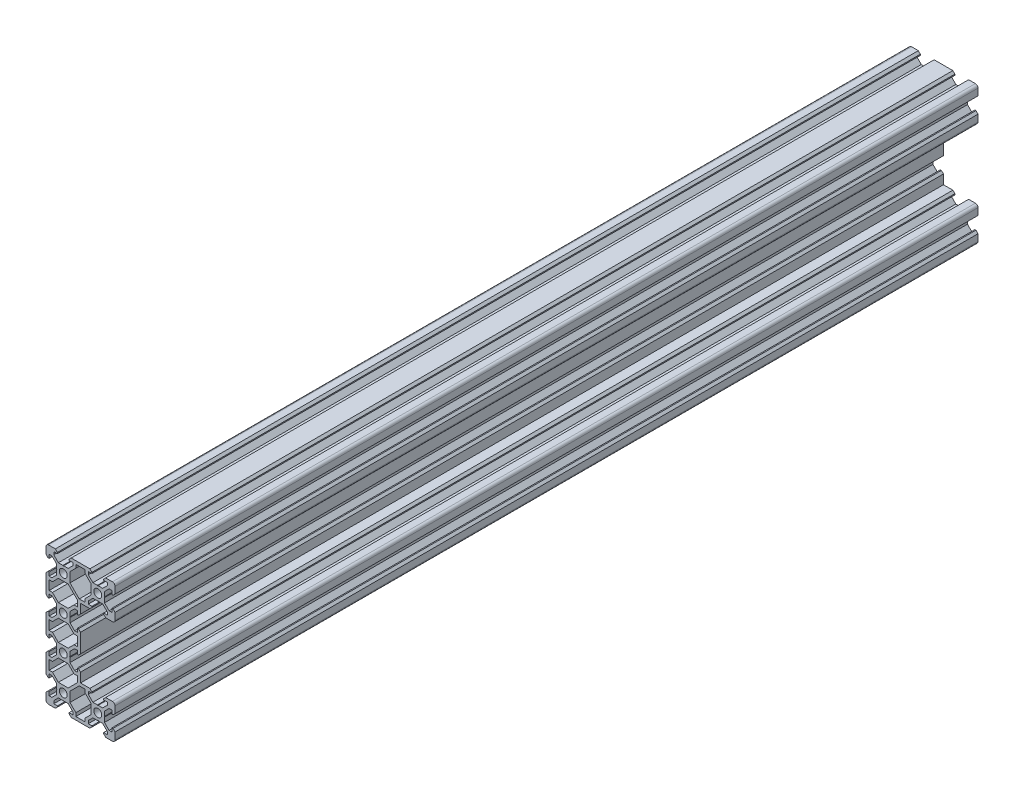
from build123d import *

# Parameters (mm, degrees)
SKETCH1_R           = 2.3
BOSS_EXTRUDE1_DEPTH = 500


with BuildPart() as part:
    # Sketch1 → Boss-Extrude1 (new body)
    with BuildSketch(Plane.XY):
        with BuildLine():
            Line((0, -5.42), (0, 5.42))
            Line((0, 5.42), (1.185, 6.605))
            Line((1.185, 6.605), (1.8, 6.605))
            Line((1.8, 6.605), (1.8, 4.5))
            Line((1.8, 4.5), (3.439339828, 4.5))
            Line((3.439339828, 4.5), (6.1, 7.160660172))
            Line((6.1, 7.160660172), (6.1, 9.79))
            Line((6.1, 9.79), (6.31, 10))
            Line((6.31, 10), (6.1, 10.21))
            Line((6.1, 10.21), (6.1, 12.839339828))
            Line((6.1, 12.839339828), (3.439339828, 15.5))
            Line((3.439339828, 15.5), (1.8, 15.5))
            Line((1.8, 15.5), (1.8, 13.395))
            Line((1.8, 13.395), (1.185, 13.395))
            Line((1.185, 13.395), (0, 14.58))
            Line((0, 14.58), (0, 25.42))
            Line((0, 25.42), (1.185, 26.605))
            Line((1.185, 26.605), (1.8, 26.605))
            Line((1.8, 26.605), (1.8, 24.5))
            Line((1.8, 24.5), (3.439339828, 24.5))
            Line((3.439339828, 24.5), (6.1, 27.160660172))
            Line((6.1, 27.160660172), (6.1, 29.79))
            Line((6.1, 29.79), (6.31, 30))
            Line((6.31, 30), (6.1, 30.21))
            Line((6.1, 30.21), (6.1, 32.839339828))
            Line((6.1, 32.839339828), (3.439339828, 35.5))
            Line((3.439339828, 35.5), (1.8, 35.5))
            Line((1.8, 35.5), (1.8, 33.395))
            Line((1.8, 33.395), (1.185, 33.395))
            Line((1.185, 33.395), (0, 34.58))
            Line((0, 34.58), (0, 38.5))
            ThreePointArc((0, 38.5), (0.439339828, 39.560660172), (1.5, 40))
            Line((1.5, 40), (5.42, 40))
            Line((5.42, 40), (6.605, 38.815))
            Line((6.605, 38.815), (6.605, 38.2))
            Line((6.605, 38.2), (4.5, 38.2))
            Line((4.5, 38.2), (4.5, 36.560660172))
            Line((4.5, 36.560660172), (7.160660172, 33.9))
            Line((7.160660172, 33.9), (9.79, 33.9))
            Line((9.79, 33.9), (10, 33.69))
            Line((10, 33.69), (10.21, 33.9))
            Line((10.21, 33.9), (12.839339828, 33.9))
            Line((12.839339828, 33.9), (15.5, 36.560660172))
            Line((15.5, 36.560660172), (15.5, 38.2))
            Line((15.5, 38.2), (13.395, 38.2))
            Line((13.395, 38.2), (13.395, 38.815))
            Line((13.395, 38.815), (14.58, 40))
            Line((14.58, 40), (25.42, 40))
            Line((25.42, 40), (26.605, 38.815))
            Line((26.605, 38.815), (26.605, 38.2))
            Line((26.605, 38.2), (24.5, 38.2))
            Line((24.5, 38.2), (24.5, 36.560660172))
            Line((24.5, 36.560660172), (27.160660172, 33.9))
            Line((27.160660172, 33.9), (29.79, 33.9))
            Line((29.79, 33.9), (30, 33.69))
            Line((30, 33.69), (30.21, 33.9))
            Line((30.21, 33.9), (32.839339828, 33.9))
            Line((32.839339828, 33.9), (35.5, 36.560660172))
            Line((35.5, 36.560660172), (35.5, 38.2))
            Line((35.5, 38.2), (33.395, 38.2))
            Line((33.395, 38.2), (33.395, 38.815))
            Line((33.395, 38.815), (34.58, 40))
            Line((34.58, 40), (38.5, 40))
            ThreePointArc((38.5, 40), (39.560660172, 39.560660172), (40, 38.5))
            Line((40, 38.5), (40, 34.58))
            Line((40, 34.58), (38.815, 33.395))
            Line((38.815, 33.395), (38.2, 33.395))
            Line((38.2, 33.395), (38.2, 35.5))
            Line((38.2, 35.5), (36.560660172, 35.5))
            Line((36.560660172, 35.5), (33.9, 32.839339828))
            Line((33.9, 32.839339828), (33.9, 30.21))
            Line((33.9, 30.21), (33.69, 30))
            Line((33.69, 30), (33.9, 29.79))
            Line((33.9, 29.79), (33.9, 27.160660172))
            Line((33.9, 27.160660172), (36.560660172, 24.5))
            Line((36.560660172, 24.5), (38.2, 24.5))
            Line((38.2, 24.5), (38.2, 26.605))
            Line((38.2, 26.605), (38.815, 26.605))
            Line((38.815, 26.605), (40, 25.42))
            Line((40, 25.42), (40, 21.5))
            ThreePointArc((40, 21.5), (39.560660172, 20.439339828), (38.5, 20))
            Line((38.5, 20), (34.58, 20))
            Line((34.58, 20), (33.395, 21.185))
            Line((33.395, 21.185), (33.395, 21.8))
            Line((33.395, 21.8), (35.5, 21.8))
            Line((35.5, 21.8), (35.5, 23.439339828))
            Line((35.5, 23.439339828), (32.839339828, 26.1))
            Line((32.839339828, 26.1), (30.21, 26.1))
            Line((30.21, 26.1), (30, 26.31))
            Line((30, 26.31), (29.79, 26.1))
            Line((29.79, 26.1), (27.160660172, 26.1))
            Line((27.160660172, 26.1), (24.5, 23.439339828))
            Line((24.5, 23.439339828), (24.5, 21.8))
            Line((24.5, 21.8), (26.605, 21.8))
            Line((26.605, 21.8), (26.605, 21.185))
            Line((26.605, 21.185), (25.42, 20))
            Line((25.42, 20), (20, 20))
            Line((20, 20), (20, 14.58))
            Line((20, 14.58), (18.815, 13.395))
            Line((18.815, 13.395), (18.2, 13.395))
            Line((18.2, 13.395), (18.2, 15.5))
            Line((18.2, 15.5), (16.560660172, 15.5))
            Line((16.560660172, 15.5), (13.9, 12.839339828))
            Line((13.9, 12.839339828), (13.9, 10.21))
            Line((13.9, 10.21), (13.69, 10))
            Line((13.69, 10), (13.9, 9.79))
            Line((13.9, 9.79), (13.9, 7.160660172))
            Line((13.9, 7.160660172), (16.560660172, 4.5))
            Line((16.560660172, 4.5), (18.2, 4.5))
            Line((18.2, 4.5), (18.2, 6.605))
            Line((18.2, 6.605), (18.815, 6.605))
            Line((18.815, 6.605), (20, 5.42))
            Line((20, 5.42), (20, -5.42))
            Line((20, -5.42), (18.815, -6.605))
            Line((18.815, -6.605), (18.2, -6.605))
            Line((18.2, -6.605), (18.2, -4.5))
            Line((18.2, -4.5), (16.560660172, -4.5))
            Line((16.560660172, -4.5), (13.9, -7.160660172))
            Line((13.9, -7.160660172), (13.9, -9.79))
            Line((13.9, -9.79), (13.69, -10))
            Line((13.69, -10), (13.9, -10.21))
            Line((13.9, -10.21), (13.9, -12.839339828))
            Line((13.9, -12.839339828), (16.560660172, -15.5))
            Line((16.560660172, -15.5), (18.2, -15.5))
            Line((18.2, -15.5), (18.2, -13.395))
            Line((18.2, -13.395), (18.815, -13.395))
            Line((18.815, -13.395), (20, -14.58))
            Line((20, -14.58), (20, -20))
            Line((20, -20), (25.42, -20))
            Line((25.42, -20), (26.605, -21.185))
            Line((26.605, -21.185), (26.605, -21.8))
            Line((26.605, -21.8), (24.5, -21.8))
            Line((24.5, -21.8), (24.5, -23.439339828))
            Line((24.5, -23.439339828), (27.160660172, -26.1))
            Line((27.160660172, -26.1), (29.79, -26.1))
            Line((29.79, -26.1), (30, -26.31))
            Line((30, -26.31), (30.21, -26.1))
            Line((30.21, -26.1), (32.839339828, -26.1))
            Line((32.839339828, -26.1), (35.5, -23.439339828))
            Line((35.5, -23.439339828), (35.5, -21.8))
            Line((35.5, -21.8), (33.395, -21.8))
            Line((33.395, -21.8), (33.395, -21.185))
            Line((33.395, -21.185), (34.58, -20))
            Line((34.58, -20), (38.5, -20))
            ThreePointArc((38.5, -20), (39.560660172, -20.439339828), (40, -21.5))
            Line((40, -21.5), (40, -25.42))
            Line((40, -25.42), (38.815, -26.605))
            Line((38.815, -26.605), (38.2, -26.605))
            Line((38.2, -26.605), (38.2, -24.5))
            Line((38.2, -24.5), (36.560660172, -24.5))
            Line((36.560660172, -24.5), (33.9, -27.160660172))
            Line((33.9, -27.160660172), (33.9, -29.79))
            Line((33.9, -29.79), (33.69, -30))
            Line((33.69, -30), (33.9, -30.21))
            Line((33.9, -30.21), (33.9, -32.839339828))
            Line((33.9, -32.839339828), (36.560660172, -35.5))
            Line((36.560660172, -35.5), (38.2, -35.5))
            Line((38.2, -35.5), (38.2, -33.395))
            Line((38.2, -33.395), (38.815, -33.395))
            Line((38.815, -33.395), (40, -34.58))
            Line((40, -34.58), (40, -38.5))
            ThreePointArc((40, -38.5), (39.560660172, -39.560660172), (38.5, -40))
            Line((38.5, -40), (34.58, -40))
            Line((34.58, -40), (33.395, -38.815))
            Line((33.395, -38.815), (33.395, -38.2))
            Line((33.395, -38.2), (35.5, -38.2))
            Line((35.5, -38.2), (35.5, -36.560660172))
            Line((35.5, -36.560660172), (32.839339828, -33.9))
            Line((32.839339828, -33.9), (30.21, -33.9))
            Line((30.21, -33.9), (30, -33.69))
            Line((30, -33.69), (29.79, -33.9))
            Line((29.79, -33.9), (27.160660172, -33.9))
            Line((27.160660172, -33.9), (24.5, -36.560660172))
            Line((24.5, -36.560660172), (24.5, -38.2))
            Line((24.5, -38.2), (26.605, -38.2))
            Line((26.605, -38.2), (26.605, -38.815))
            Line((26.605, -38.815), (25.42, -40))
            Line((25.42, -40), (14.58, -40))
            Line((14.58, -40), (13.395, -38.815))
            Line((13.395, -38.815), (13.395, -38.2))
            Line((13.395, -38.2), (15.5, -38.2))
            Line((15.5, -38.2), (15.5, -36.560660172))
            Line((15.5, -36.560660172), (12.839339828, -33.9))
            Line((12.839339828, -33.9), (10.21, -33.9))
            Line((10.21, -33.9), (10, -33.69))
            Line((10, -33.69), (9.79, -33.9))
            Line((9.79, -33.9), (7.160660172, -33.9))
            Line((7.160660172, -33.9), (4.5, -36.560660172))
            Line((4.5, -36.560660172), (4.5, -38.2))
            Line((4.5, -38.2), (6.605, -38.2))
            Line((6.605, -38.2), (6.605, -38.815))
            Line((6.605, -38.815), (5.42, -40))
            Line((5.42, -40), (1.5, -40))
            ThreePointArc((1.5, -40), (0.439339828, -39.560660172), (0, -38.5))
            Line((0, -38.5), (0, -34.58))
            Line((0, -34.58), (1.185, -33.395))
            Line((1.185, -33.395), (1.8, -33.395))
            Line((1.8, -33.395), (1.8, -35.5))
            Line((1.8, -35.5), (3.439339828, -35.5))
            Line((3.439339828, -35.5), (6.1, -32.839339828))
            Line((6.1, -32.839339828), (6.1, -30.21))
            Line((6.1, -30.21), (6.31, -30))
            Line((6.31, -30), (6.1, -29.79))
            Line((6.1, -29.79), (6.1, -27.160660172))
            Line((6.1, -27.160660172), (3.439339828, -24.5))
            Line((3.439339828, -24.5), (1.8, -24.5))
            Line((1.8, -24.5), (1.8, -26.605))
            Line((1.8, -26.605), (1.185, -26.605))
            Line((1.185, -26.605), (0, -25.42))
            Line((0, -25.42), (0, -14.58))
            Line((0, -14.58), (1.185, -13.395))
            Line((1.185, -13.395), (1.8, -13.395))
            Line((1.8, -13.395), (1.8, -15.5))
            Line((1.8, -15.5), (3.439339828, -15.5))
            Line((3.439339828, -15.5), (6.1, -12.839339828))
            Line((6.1, -12.839339828), (6.1, -10.21))
            Line((6.1, -10.21), (6.31, -10))
            Line((6.31, -10), (6.1, -9.79))
            Line((6.1, -9.79), (6.1, -7.160660172))
            Line((6.1, -7.160660172), (3.439339828, -4.5))
            Line((3.439339828, -4.5), (1.8, -4.5))
            Line((1.8, -4.5), (1.8, -6.605))
            Line((1.8, -6.605), (1.185, -6.605))
            Line((1.185, -6.605), (0, -5.42))
        make_face()
        with Locations((30, -30)):
            Circle(SKETCH1_R, mode=Mode.SUBTRACT)
        with Locations((30, 30)):
            Circle(SKETCH1_R, mode=Mode.SUBTRACT)
        with Locations((10, 30)):
            Circle(SKETCH1_R, mode=Mode.SUBTRACT)
        with Locations((10, 10)):
            Circle(SKETCH1_R, mode=Mode.SUBTRACT)
        with Locations((10, -10)):
            Circle(SKETCH1_R, mode=Mode.SUBTRACT)
        with Locations((10, -30)):
            Circle(SKETCH1_R, mode=Mode.SUBTRACT)
        Polygon((17.3, 38.2), (17.3, 36.239339828), (13.9, 32.839339828), (13.9, 27.160660172), (19.260660172, 21.8), (22.7, 21.8), (22.7, 23.760660172), (26.1, 27.160660172), (26.1, 32.839339828), (22.7, 36.239339828), (22.7, 38.2), align=None, mode=Mode.SUBTRACT)
        Polygon((1.8, -22.7), (3.760660172, -22.7), (7.160660172, -26.1), (12.839339828, -26.1), (18.2, -20.739339828), (18.2, -17.3), (16.239339828, -17.3), (12.839339828, -13.9), (7.160660172, -13.9), (3.760660172, -17.3), (1.8, -17.3), align=None, mode=Mode.SUBTRACT)
        Polygon((22.7, -38.2), (22.7, -36.239339828), (26.1, -32.839339828), (26.1, -27.160660172), (22.7, -23.760660172), (22.7, -21.8), (19.260660172, -21.8), (13.9, -27.160660172), (13.9, -32.839339828), (17.3, -36.239339828), (17.3, -38.2), align=None, mode=Mode.SUBTRACT)
        Polygon((1.8, 17.3), (3.760660172, 17.3), (7.160660172, 13.9), (12.839339828, 13.9), (16.239339828, 17.3), (18.2, 17.3), (18.2, 20.739339828), (12.839339828, 26.1), (7.160660172, 26.1), (3.760660172, 22.7), (1.8, 22.7), align=None, mode=Mode.SUBTRACT)
        Polygon((1.8, -2.7), (3.760660172, -2.7), (7.160660172, -6.1), (12.839339828, -6.1), (16.239339828, -2.7), (18.2, -2.7), (18.2, 2.7), (16.239339828, 2.7), (12.839339828, 6.1), (7.160660172, 6.1), (3.760660172, 2.7), (1.8, 2.7), align=None, mode=Mode.SUBTRACT)
    extrude(amount=BOSS_EXTRUDE1_DEPTH)


solid = part.part
